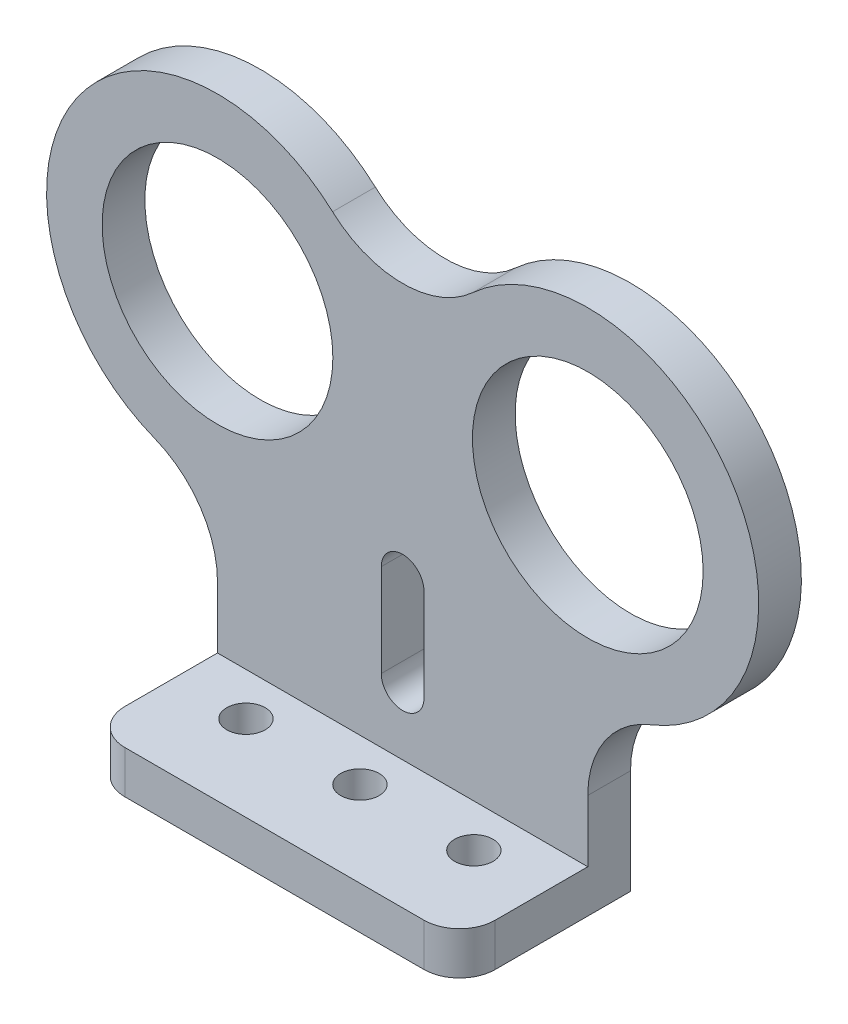
from build123d import *

# Parameters (mm, degrees)
SKETCH1_R           = 8.1
BOSS_EXTRUDE1_DEPTH = 3
SKETCH3_R           = 1.35
BOSS_EXTRUDE2_DEPTH = 3


with BuildPart() as part:
    # Sketch1 → Boss-Extrude1 (new body)
    with BuildSketch(Plane.XY):
        with BuildLine():
            Line((-13, 7.336478267), (-13, 0))
            Line((-13, 0), (13, 0))
            Line((13, 0), (13, 7.336478267))
            ThreePointArc((13, 7.336478267), (14.209808657, 11.270138676), (17.421052632, 13.844091537))
            ThreePointArc((17.421052632, 13.844091537), (22.926042302, 18.256582157), (25, 25))
            ThreePointArc((25, 25), (17.848843081, 35.976735433), (4.918546537, 33.87074461))
            ThreePointArc((4.918546537, 33.87074461), (0, 31.966212419), (-4.918546537, 33.87074461))
            ThreePointArc((-4.918546537, 33.87074461), (-17.848843081, 35.976735433), (-25, 25))
            ThreePointArc((-25, 25), (-22.926042302, 18.256582157), (-17.421052632, 13.844091537))
            ThreePointArc((-17.421052632, 13.844091537), (-14.209808657, 11.270138676), (-13, 7.336478267))
        make_face()
        with BuildLine():
            ThreePointArc((-1.5, 14), (0, 15.5), (1.5, 14))
            Line((1.5, 14), (1.5, 7.5))
            ThreePointArc((1.5, 7.5), (0, 6), (-1.5, 7.5))
            Line((-1.5, 7.5), (-1.5, 14))
        make_face(mode=Mode.SUBTRACT)
        with Locations((-13, 25)):
            Circle(SKETCH1_R, mode=Mode.SUBTRACT)
        with Locations((13, 25)):
            Circle(SKETCH1_R, mode=Mode.SUBTRACT)
    extrude(amount=BOSS_EXTRUDE1_DEPTH)

    # Sketch3 → Boss-Extrude2 (add)
    with BuildSketch(Plane.XZ):
        with BuildLine():
            Line((-13, 3), (13, 3))
            Line((13, 3), (13, 9.5))
            ThreePointArc((13, 9.5), (12.267766953, 11.267766953), (10.5, 12))
            Line((10.5, 12), (-10.5, 12))
            ThreePointArc((-10.5, 12), (-12.267766953, 11.267766953), (-13, 9.5))
            Line((-13, 9.5), (-13, 3))
        make_face()
        with Locations((8, 6)):
            Circle(SKETCH3_R, mode=Mode.SUBTRACT)
        with Locations((-8, 6)):
            Circle(SKETCH3_R, mode=Mode.SUBTRACT)
        with Locations((0, 6)):
            Circle(SKETCH3_R, mode=Mode.SUBTRACT)
    extrude(amount=-BOSS_EXTRUDE2_DEPTH)


solid = part.part
